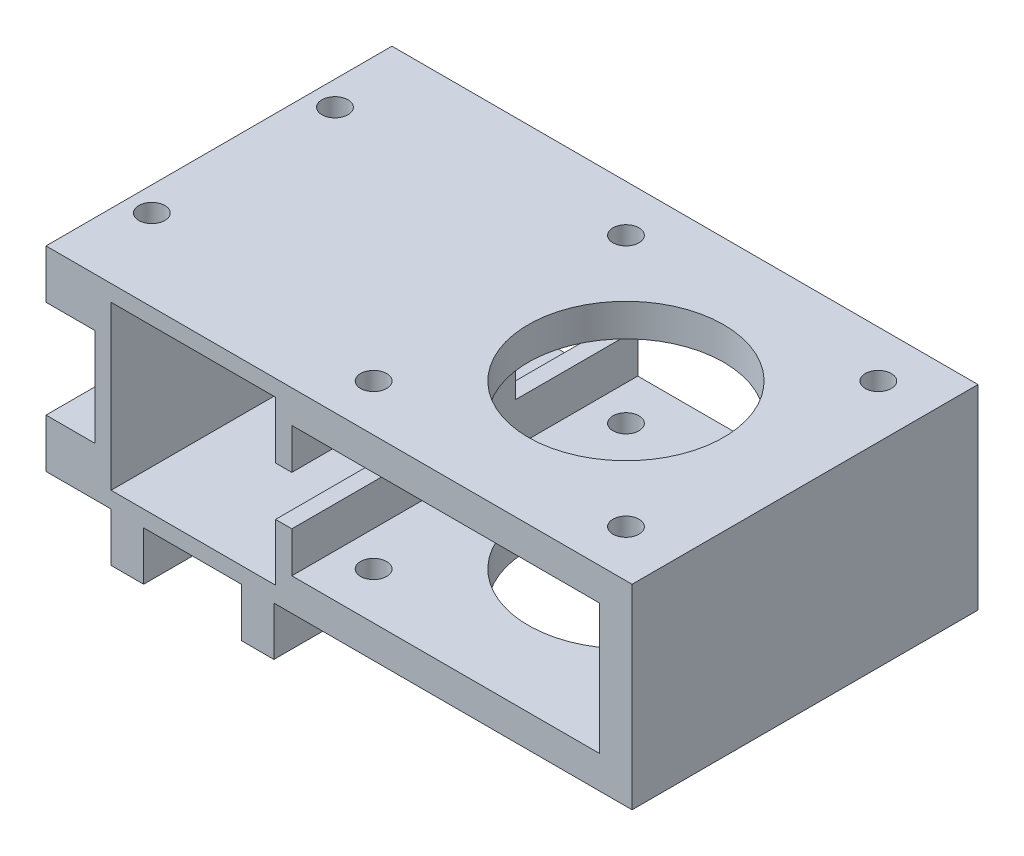
from build123d import *

# Parameters (mm, degrees)
ESQUISSE1_W             = 20.2
ESQUISSE1_H             = 20
ESQUISSE1_W_2           = 37.8
ESQUISSE1_H_2           = 16
BOSS_EXTRU_1_DEPTH      = 42.5
ESQUISSE2_R             = 12
ENL_V_MAT_EXTRU_1_DEPTH = 25
D_GAGEMENT_M31_D        = 3.2
D_GAGEMENT_M32_D        = 3.2
D_GAGEMENT_M33_D        = 3.2
ENL_V_MAT_EXTRU_2_REACH = 32.2
ESQUISSE11_W            = 15
ESQUISSE11_H            = 6


with BuildPart() as part:
    # Esquisse1 → Boss.-Extru.1 (new body)
    with BuildSketch(Plane.XY):
        Polygon((0, 0), (72, 0), (72, -24), (28, -24), (28, -30), (24, -30), (24, -24), (12, -24), (12, -30), (8, -30), (8, -24), (0, -24), (0, -18), (6, -18), (6, -6), (0, -6), align=None)
        with Locations((18.1, -12)):
            Rectangle(ESQUISSE1_W, ESQUISSE1_H, mode=Mode.SUBTRACT)
        with Locations((49.1, -12)):
            Rectangle(ESQUISSE1_W_2, ESQUISSE1_H_2, mode=Mode.SUBTRACT)
    extrude(amount=BOSS_EXTRU_1_DEPTH)

    # Esquisse2 → Enlèv. mat.-Extru.1 (cut, through all)
    with BuildSketch(Plane.XZ.offset(24)):
        with Locations((50, 21.25)):
            Circle(ESQUISSE2_R)
    extrude(amount=-ENL_V_MAT_EXTRU_1_DEPTH, mode=Mode.SUBTRACT)

    # Dégagement M31 (through all)
    with Locations(Plane(origin=(0, -24, 0), x_dir=(-1, 0, 0), z_dir=(0, -1, 0))):
        with Locations((-50, -21.25), (-34.5, -5.75), (-65.5, -36.75), (-65.5, -5.75), (-34.5, -36.75)):
            Hole(D_GAGEMENT_M31_D / 2)

    # Dégagement M32 (through all)
    with Locations(Plane(origin=(28, 0, 0), x_dir=(0, 0, -1), z_dir=(1, 0, 0))):
        with Locations((-10, -27), (-32.5, -27)):
            Hole(D_GAGEMENT_M32_D / 2)

    # Dégagement M33 (through all)
    with Locations(Plane(origin=(0, -24, 0), x_dir=(-1, 0, 0), z_dir=(0, -1, 0))):
        with Locations((-3, -10), (-3, -32.5)):
            Hole(D_GAGEMENT_M33_D / 2)

    # Esquisse11 → Enlèv. mat.-Extru.2 (cut, up to next)
    with BuildSketch(Plane(origin=(30.2, 0, 0), x_dir=(0, 0, -1), z_dir=(1, 0, 0)), mode=Mode.PRIVATE) as enl_v_mat_extru_2_sk1:
        with Locations((-7.5, -12)):
            Rectangle(ESQUISSE11_W, ESQUISSE11_H)
    enl_v_mat_extru_2_tool1 = extrude(enl_v_mat_extru_2_sk1.sketch, amount=-ENL_V_MAT_EXTRU_2_REACH, mode=Mode.PRIVATE) & part.part
    add(enl_v_mat_extru_2_tool1.solids().sort_by_distance((30.2, -12, 7.5))[0], mode=Mode.SUBTRACT)
    # Esquisse11 → Enlèv. mat.-Extru.2 (cut, up to next)
    with BuildSketch(Plane(origin=(30.2, 0, 0), x_dir=(0, 0, -1), z_dir=(1, 0, 0)), mode=Mode.PRIVATE) as enl_v_mat_extru_2_sk2:
        with Locations((-35, -12)):
            Rectangle(ESQUISSE11_W, ESQUISSE11_H)
    enl_v_mat_extru_2_tool2 = extrude(enl_v_mat_extru_2_sk2.sketch, amount=-ENL_V_MAT_EXTRU_2_REACH, mode=Mode.PRIVATE) & part.part
    add(enl_v_mat_extru_2_tool2.solids().sort_by_distance((30.2, -12, 35))[0], mode=Mode.SUBTRACT)


solid = part.part
